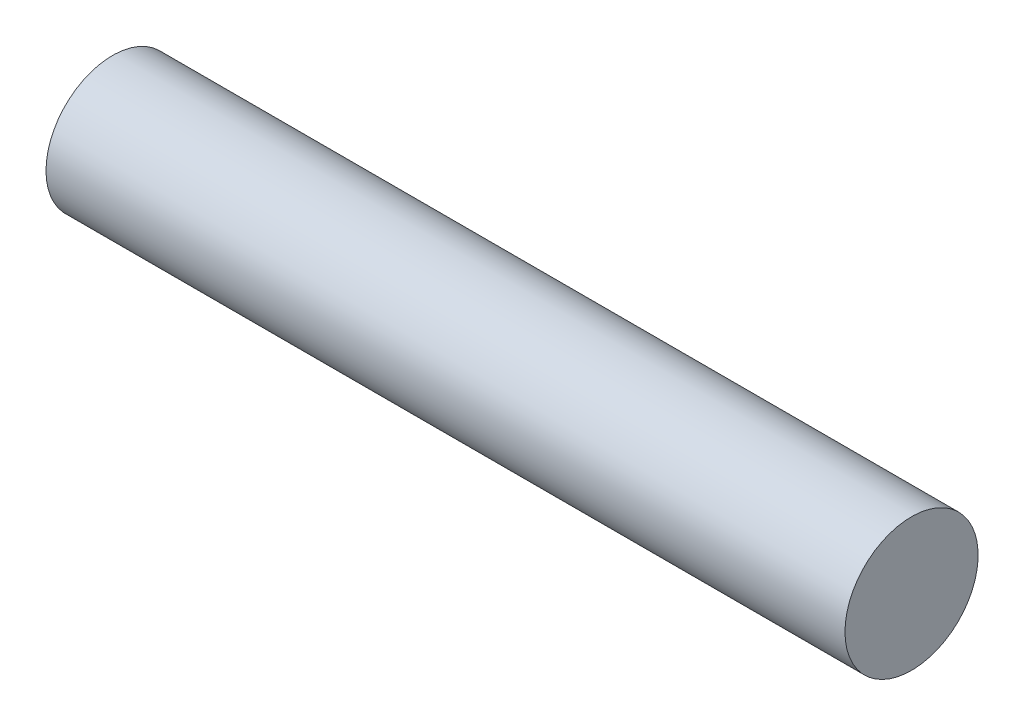
from build123d import *


with BuildPart() as part:
    # Sketch1 → Revolve2 (revolve)
    with BuildSketch(Plane.XY):
        Polygon((6, 44), (594, 44), (594, 0), (600, 0), (600, 50), (0, 50), (0, 44), align=None)
    revolve(axis=Axis((0, 0, 0), (1, 0, 0)))


solid = part.part
